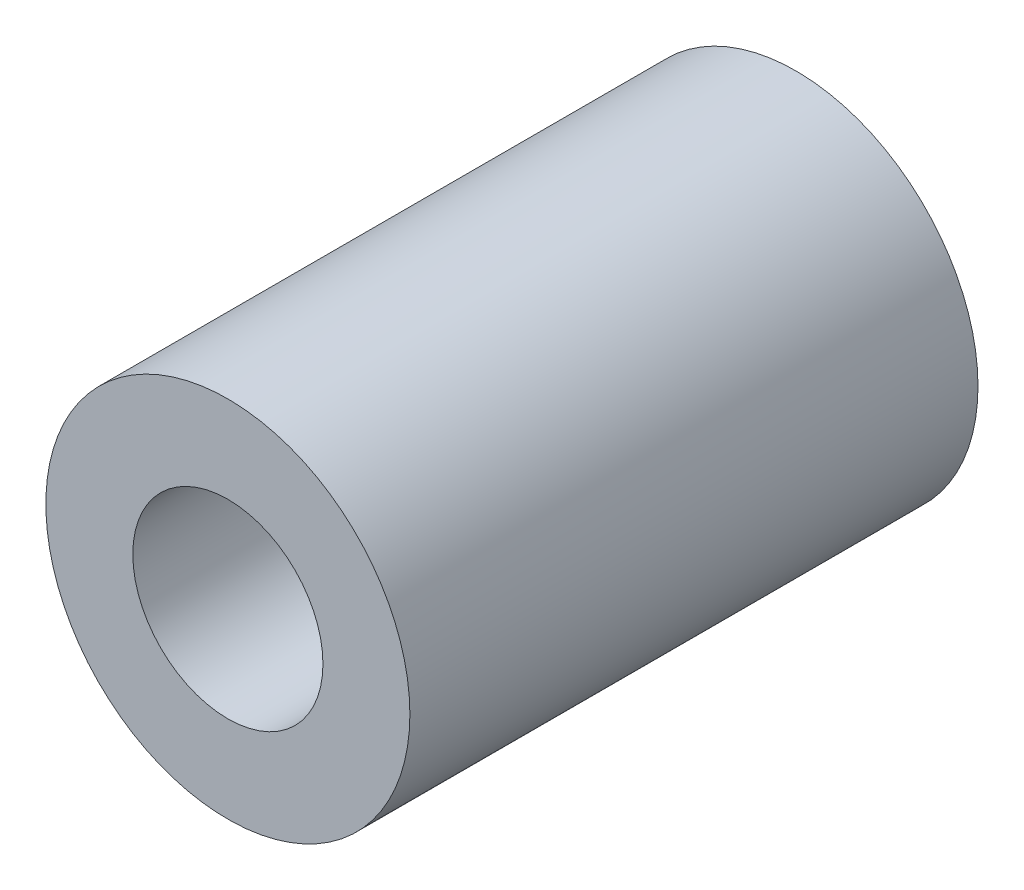
from build123d import *

# Parameters (mm, degrees)
SKETCH1_R           = 7.85
SKETCH1_R_2         = 4.1
BOSS_EXTRUDE1_DEPTH = 24.5


with BuildPart() as part:
    # Sketch1 → Boss-Extrude1 (new body)
    with BuildSketch(Plane.XY):
        Circle(SKETCH1_R)
        Circle(SKETCH1_R_2, mode=Mode.SUBTRACT)
    extrude(amount=BOSS_EXTRUDE1_DEPTH)


solid = part.part
